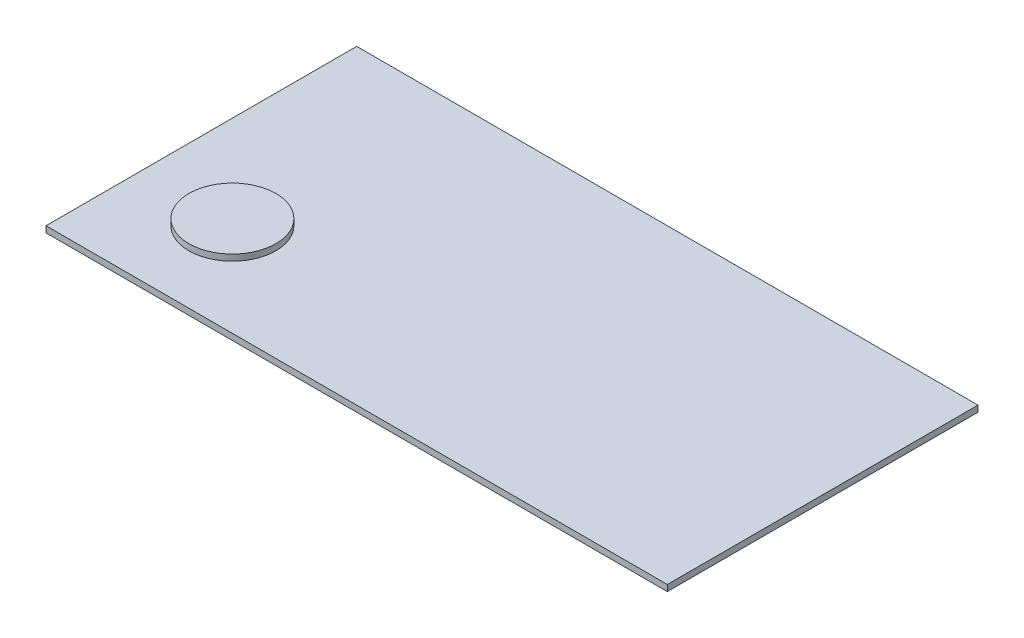
from build123d import *

# Parameters (mm, degrees)
SKETCH1_W           = 1000
SKETCH1_H           = 500
BOSS_EXTRUDE1_DEPTH = 10
SKETCH2_R           = 70
BOSS_EXTRUDE2_DEPTH = 10


with BuildPart() as part:
    # Sketch1 → Boss-Extrude1 (new body)
    with BuildSketch(Plane(origin=(0, 0, 0), x_dir=(1, 0, 0), z_dir=(0, 1, 0))):
        Rectangle(SKETCH1_W, SKETCH1_H)
    extrude(amount=BOSS_EXTRUDE1_DEPTH)

    # Sketch2 → Boss-Extrude2 (add)
    with BuildSketch(Plane(origin=(0, 10, 0), x_dir=(1, 0, 0), z_dir=(0, 1, 0))):
        with Locations((-350, -100)):
            Circle(SKETCH2_R)
    extrude(amount=BOSS_EXTRUDE2_DEPTH)


solid = part.part
